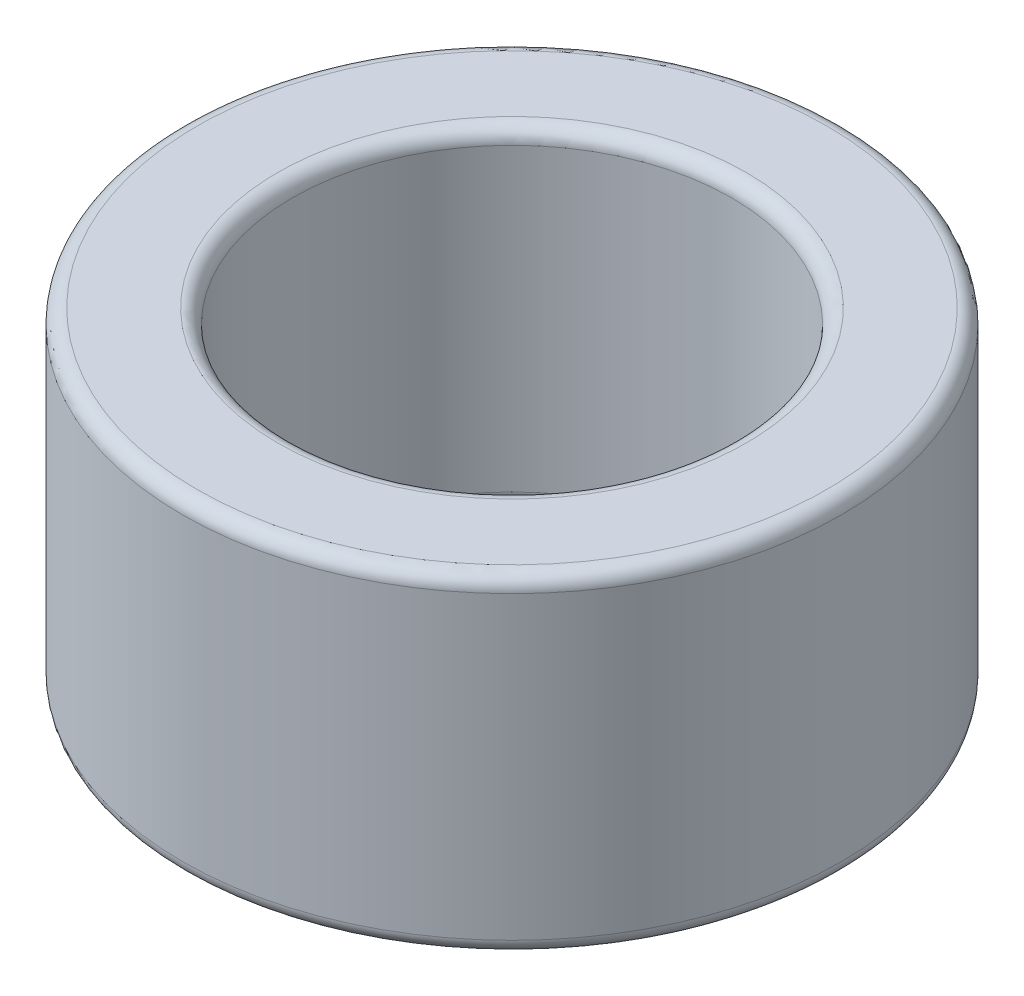
from build123d import *

# Parameters (mm, degrees)
SKETCH_1_R      = 22.5
SKETCH_1_R_2    = 15
EXTRUDE_1_DEPTH = 22.5
FILLET_1_R      = 1
FILLET_2_R      = 1


with BuildPart() as part:
    # 草图1 → 凸台-拉伸1 (new body)
    with BuildSketch(Plane(origin=(0, 0, 0), x_dir=(1, 0, 0), z_dir=(0, 1, 0))):
        Circle(SKETCH_1_R)
        Circle(SKETCH_1_R_2, mode=Mode.SUBTRACT)
    extrude(amount=EXTRUDE_1_DEPTH)

    # 圆角1
    fillet_1_edges = [part.edges().sort_by_distance(p)[0] for p in [
        (-22.5, 22.5, 0),
    ]]
    fillet(fillet_1_edges, radius=FILLET_1_R)

    # 圆角2
    fillet_2_edges = [part.edges().sort_by_distance(p)[0] for p in [
        (-22.5, 0, 0),
        (-15, 0, 0),
        (-15, 22.5, 0),
    ]]
    fillet(fillet_2_edges, radius=FILLET_2_R)


solid = part.part
